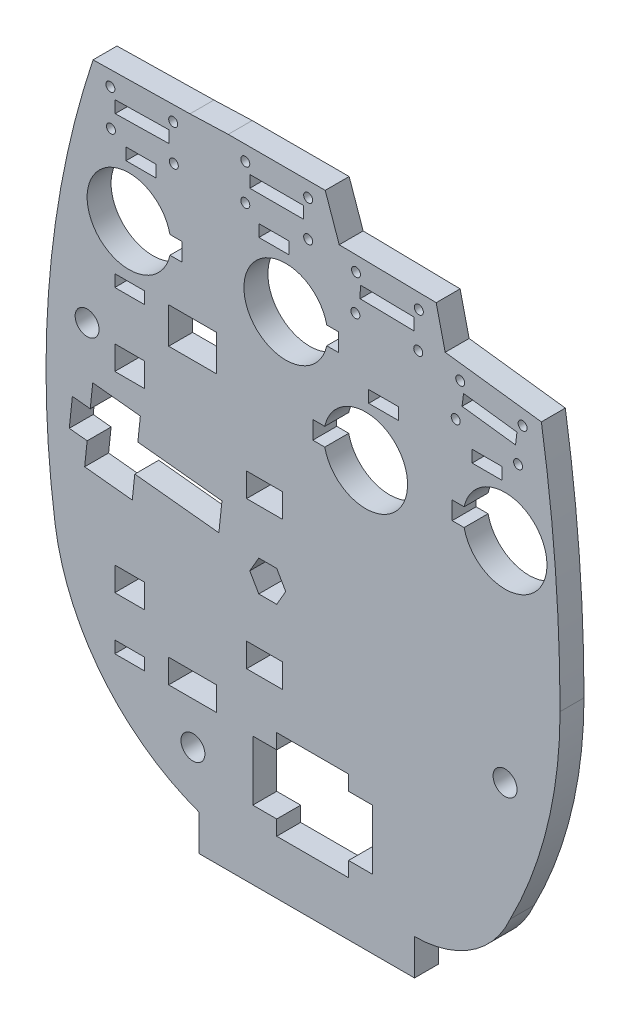
from build123d import *

# Parameters (mm, degrees)
SKETCH1_R           = 2
SKETCH1_R_2         = 0.75
SKETCH1_R_3         = 0.74964
SKETCH1_W           = 9
SKETCH1_H           = 2.000000357
SKETCH1_W_2         = 5
SKETCH1_H_2         = 2
SKETCH1_W_3         = 8
SKETCH1_H_3         = 6.000000353
SKETCH1_H_4         = 4
SKETCH1_W_4         = 6.000000352
BOSS_EXTRUDE1_DEPTH = 4


with BuildPart() as part:
    # Sketch1 → Boss-Extrude1 (new body)
    with BuildSketch(Plane.XY):
        with BuildLine():
            Line((-12.978641063, -17.999999648), (-12.978641063, -24))
            Line((-12.978641063, -24), (23.021361236, -24))
            Line((23.021361236, -24), (23.021361236, -17.999999648))
            ThreePointArc((23.021361236, -17.999999648), (32.577630228, -15.139859344), (38.991305368, -7.5))
            ThreePointArc((38.991305368, -7.5), (45.219254131, 9.097839331), (47.3354431, 26.698900677))
            ThreePointArc((47.3354431, 26.698900677), (46.554459277, 46.942107237), (44.216150624, 67.064971353))
            Line((44.216150624, 67.064971353), (28.143849376, 69.095028647))
            Line((28.143849376, 69.095028647), (26.638766331, 75.523635508))
            Line((26.638766331, 75.523635508), (10.441233669, 75.806364492))
            Line((10.441233669, 75.806364492), (8.1, 82.51))
            Line((8.1, 82.51), (-8.1, 82.51))
            Line((-8.1, 82.51), (-14.491235706, 82.281481113))
            Line((-14.491235706, 82.281481113), (-30.688764294, 81.998518887))
            ThreePointArc((-30.688764294, 81.998518887), (-37.914532987, 47.276776451), (-37.052658257, 11.821617405))
            ThreePointArc((-37.052658257, 11.821617405), (-29.143237496, -6.421257936), (-12.978641063, -17.999999648))
        make_face()
        with Locations((38.147341743, 11.821617405)):
            Circle(SKETCH1_R, mode=Mode.SUBTRACT)
        with Locations((-14, -9.124358764)):
            Circle(SKETCH1_R, mode=Mode.SUBTRACT)
        with Locations((-5.25, 80.01)):
            Circle(SKETCH1_R_2, mode=Mode.SUBTRACT)
        with Locations((-31.681501662, 43.456405989)):
            Circle(SKETCH1_R, mode=Mode.SUBTRACT)
        with Locations((5.25, 80.01)):
            Circle(SKETCH1_R_2, mode=Mode.SUBTRACT)
        with Locations((5.25, 74.01)):
            Circle(SKETCH1_R_2, mode=Mode.SUBTRACT)
        with Locations((-5.25, 74.01)):
            Circle(SKETCH1_R_2, mode=Mode.SUBTRACT)
        with Locations((-27.795567347, 79.548639007)):
            Circle(SKETCH1_R_2, mode=Mode.SUBTRACT)
        with Locations((-17.297097199, 79.732041708)):
            Circle(SKETCH1_R_2, mode=Mode.SUBTRACT)
        with Locations((-27.690766522, 73.549554345)):
            Circle(SKETCH1_R_2, mode=Mode.SUBTRACT)
        with Locations((-17.192296374, 73.732957046)):
            Circle(SKETCH1_R_2, mode=Mode.SUBTRACT)
        with Locations((23.640854945, 67.074669457)):
            Circle(SKETCH1_R_2, mode=Mode.SUBTRACT)
        with Locations((13.142454146, 67.257919725)):
            Circle(SKETCH1_R_2, mode=Mode.SUBTRACT)
        with Locations((23.745569383, 73.073755628)):
            Circle(SKETCH1_R_2, mode=Mode.SUBTRACT)
        with Locations((13.247168584, 73.257005896)):
            Circle(SKETCH1_R_2, mode=Mode.SUBTRACT)
        with Locations((29.906230336, 60.30489137)):
            Circle(SKETCH1_R_3, mode=Mode.SUBTRACT)
        with Locations((41.075335698, 64.94181766)):
            Circle(SKETCH1_R_3, mode=Mode.SUBTRACT)
        with Locations((30.658103408, 66.257595536)):
            Circle(SKETCH1_R_3, mode=Mode.SUBTRACT)
        with Locations((40.323462626, 58.989113494)):
            Circle(SKETCH1_R_3, mode=Mode.SUBTRACT)
        with Locations((0, 77.509999822)):
            Rectangle(SKETCH1_W, SKETCH1_H, mode=Mode.SUBTRACT)
        Polygon((-9.666, 24.072257636), (-9.153, 28.953126601), (-23.204098338, 30.429956546), (-22.785984485, 34.408044128), (-30.742159647, 35.244271834), (-31.160273501, 31.266184253), (-34.143839187, 31.579769642), (-34.656839187, 26.698900677), (-31.673273501, 26.385315288), (-32.091387354, 22.407227706), (-24.135212191, 21.571), (-23.717098338, 25.549087581), align=None, mode=Mode.SUBTRACT)
        with BuildLine():
            Line((10.358817838, 63.151218734), (10.358817838, 60.151218734))
            Line((10.358817838, 60.151218734), (8.358817838, 60.151218734))
            ThreePointArc((8.358817838, 60.151218734), (-5.478579327, 61.651218734), (8.358817838, 63.151218734))
            Line((8.358817838, 63.151218734), (10.358817838, 63.151218734))
        make_face(mode=Mode.SUBTRACT)
        with Locations((35.147341743, 56.321617405)):
            Rectangle(SKETCH1_W_2, SKETCH1_H_2, mode=Mode.SUBTRACT)
        with BuildLine():
            Line((-17.84156291, 63.151218734), (-15.84156291, 63.151218734))
            Line((-15.84156291, 63.151218734), (-15.84156291, 60.151218734))
            Line((-15.84156291, 60.151218734), (-17.84156291, 60.151218734))
            ThreePointArc((-17.84156291, 60.151218734), (-31.678960076, 61.651218734), (-17.84156291, 63.151218734))
        make_face(mode=Mode.SUBTRACT)
        Polygon((-27.019482275, 78.062008978), (-18.020783292, 78.219211472), (-17.985849684, 76.219516585), (-26.984548667, 76.06231409), align=None, mode=Mode.SUBTRACT)
        with Locations((-14.054335075, 49.87557619)):
            Rectangle(SKETCH1_W_3, SKETCH1_H_3, mode=Mode.SUBTRACT)
        with Locations((17.86306514, 56.321617405)):
            Rectangle(SKETCH1_W_2, SKETCH1_H_2, mode=Mode.SUBTRACT)
        with Locations((-0.478579327, 71.151218734)):
            Rectangle(SKETCH1_W_2, SKETCH1_H_2, mode=Mode.SUBTRACT)
        Polygon((13.970875746, 71.744145048), (13.935970927, 69.744449301), (22.934600183, 69.587377643), (22.969505002, 71.58707339), align=None, mode=Mode.SUBTRACT)
        with BuildLine():
            Line((8.025667975, 48.321617405), (6.025667975, 48.321617405))
            Line((6.025667975, 48.321617405), (6.025667975, 45.321617405))
            Line((6.025667975, 45.321617405), (8.025667975, 45.321617405))
            ThreePointArc((8.025667975, 45.321617405), (21.86306514, 46.821617405), (8.025667975, 48.321617405))
        make_face(mode=Mode.SUBTRACT)
        Polygon((40.143636572, 63.54758064), (31.213865999, 64.675480473), (30.963241642, 62.691245751), (39.893012214, 61.563345918), align=None, mode=Mode.SUBTRACT)
        with BuildLine():
            Line((29.309944577, 45.321617405), (31.309944577, 45.321617405))
            ThreePointArc((31.309944577, 45.321617405), (45.147341743, 46.821617405), (31.309944577, 48.321617405))
            Line((31.309944577, 48.321617405), (29.309944577, 48.321617405))
            Line((29.309944577, 48.321617405), (29.309944577, 45.321617405))
        make_face(mode=Mode.SUBTRACT)
        with Locations((-22.678960076, 71.151218734)):
            Rectangle(SKETCH1_W_2, SKETCH1_H_2, mode=Mode.SUBTRACT)
        Polygon((-4, -2.5), (0, -2.5), (0, 0), (12, 0), (12, -2.5), (16, -2.5), (16, -12.5), (12, -12.5), (12, -15), (0, -15), (0, -12.5), (-4, -12.5), align=None, mode=Mode.SUBTRACT)
        with Locations((-24.554335075, 51.875576367)):
            Rectangle(SKETCH1_W_2, SKETCH1_H_2, mode=Mode.SUBTRACT)
        with Locations((-14.054335075, -0.124358764)):
            Rectangle(SKETCH1_W_3, SKETCH1_H_4, mode=Mode.SUBTRACT)
        with Locations((-24.554335075, -1.124358764)):
            Rectangle(SKETCH1_W_2, SKETCH1_H_2, mode=Mode.SUBTRACT)
        Polygon((0, 23.754659123), (-3, 23.754659123), (-4.5, 21.156582912), (-3, 18.5585067), (0, 18.5585067), (1.5, 21.156582912), align=None, mode=Mode.SUBTRACT)
        with Locations((-2.036620161, 8.717005814)):
            Rectangle(SKETCH1_W_4, SKETCH1_H_4, mode=Mode.SUBTRACT)
        with Locations((-2.036620161, 33.335566927)):
            Rectangle(SKETCH1_W_4, SKETCH1_H_4, mode=Mode.SUBTRACT)
        with Locations((-24.554335075, 8.717005814)):
            Rectangle(SKETCH1_W_2, SKETCH1_H_4, mode=Mode.SUBTRACT)
        with Locations((-24.554335075, 40.727245232)):
            Rectangle(SKETCH1_W_2, SKETCH1_H_4, mode=Mode.SUBTRACT)
    extrude(amount=BOSS_EXTRUDE1_DEPTH)


solid = part.part
